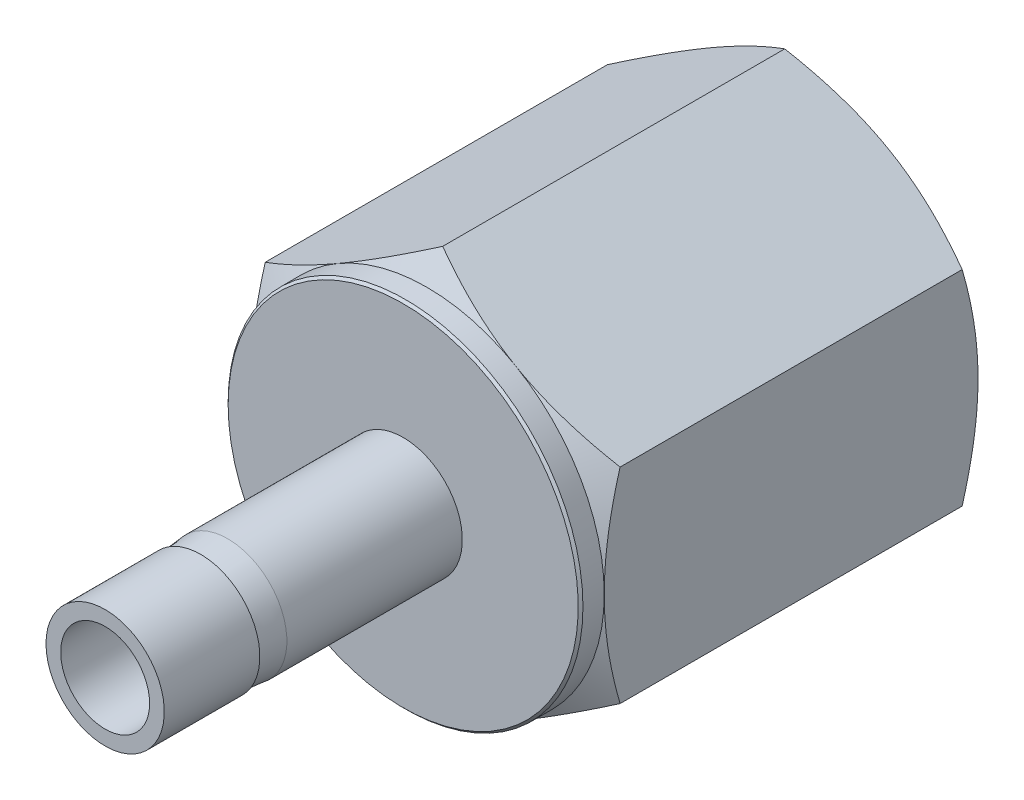
from build123d import *

# Parameters (mm, degrees)
BOSS_EXTRUDE1_DEPTH    = 21.336
SKETCH4_W              = 37.338
SKETCH4_H              = 2.3876
CHAMFER1_SIZE          = 0.127
CUT_SWEEP1_PITCH       = 1.411794907
CUT_SWEEP1_HEIGHT      = 16.513951111
CUT_SWEEP1_RADIUS      = 6.858
CUT_SWEEP1_START_ANGLE = 90


with BuildPart() as part:
    # Sketch2 → Revolve1 (revolve)
    with BuildSketch(Plane(origin=(0, 0, 0), x_dir=(0, 0, -1), z_dir=(1, 0, 0)), mode=Mode.PRIVATE) as revolve1_sk:
        Polygon((5.1308, 3.175), (5.1308, 3.048), (6.582416642, 3.175), (16.002, 3.175), (16.002, 0), (0, 0), (0, 3.175), align=None)
    revolve(revolve1_sk.sketch.rotate(Axis((0, 0, -16.002), (0, 0, 1)), 90), axis=Axis((0, 0, -16.002), (0, 0, 1)))

    # Sketch3 → Boss-Extrude1 (add)
    with BuildSketch(Plane(origin=(0, 0, -16.002), x_dir=(-1, 0, 0), z_dir=(0, 0, -1))):
        Polygon((0, 10.998522628), (-9.525, 5.499261314), (-9.525, -5.499261314), (0, -10.998522628), (9.525, -5.499261314), (9.525, 5.499261314), align=None)
    extrude(amount=BOSS_EXTRUDE1_DEPTH)

    # Sketch4 → Cut-Revolve1 (revolve, cut)
    with BuildSketch(Plane(origin=(0, 0, 0), x_dir=(0, 0, -1), z_dir=(1, 0, 0)), mode=Mode.PRIVATE) as cut_revolve1_sk:
        Polygon((16.002, 10.998522628), (16.002, 9.525), (17.272, 9.525), (18.122738686, 10.998522628), (36.487261314, 10.998522628), (37.338, 9.525), (37.338, 10.998522628), (37.338, 12.472045256), (16.002, 12.472045256), align=None)
        with Locations((18.669, 1.1938)):
            Rectangle(SKETCH4_W, SKETCH4_H)
    revolve(cut_revolve1_sk.sketch.rotate(Axis((0, 0, 0), (0, 0, -1)), 90), axis=Axis((0, 0, 0), (0, 0, -1)), mode=Mode.SUBTRACT)

    # Chamfer1
    chamfer1_edges = [part.edges().sort_by_distance(p)[0] for p in [
        (-9.525, 0, -16.002),
    ]]
    chamfer(chamfer1_edges, length=CHAMFER1_SIZE)


with BuildPart() as body_2:
    # Sketch5 → Revolve2 (revolve)
    with BuildSketch(Plane(origin=(0, 0, 0), x_dir=(0, 0, -1), z_dir=(1, 0, 0)), mode=Mode.PRIVATE) as revolve2_sk:
        Polygon((27.13228, 0), (37.338, 0), (37.338, 6.858), (27.13228, 6.540243957), align=None)
    revolve(revolve2_sk.sketch.rotate(Axis((0, 0, -27.13228), (0, 0, -1)), 270), axis=Axis((0, 0, -27.13228), (0, 0, -1)))

    # Cut-Sweep1: sweep along a helix
    with BuildLine() as cut_sweep1_path:
        # a taper helix: rise per turn along the axis 1.411111111, along the cone's slant (build123d's pitch) 1.411794907
        add(Helix(CUT_SWEEP1_PITCH, CUT_SWEEP1_HEIGHT, CUT_SWEEP1_RADIUS, center=(0, 0, -37.338), direction=(0, 0, 1), cone_angle=-1.783333333, mode=Mode.PRIVATE).rotate(Axis((0, 0, -37.338), (0, 0, 1)), CUT_SWEEP1_START_ANGLE))
    # Sketch7 → Cut-Sweep1 (sweep, cut)
    with BuildSketch(Plane(origin=(0, 0, 0), x_dir=(0, 0, -1), z_dir=(1, 0, 0))):
        Polygon((37.249805556, 7.010757259), (38.616819444, 6.934378629), (38.043555556, 5.941456448), (37.867166667, 5.941456448), align=None)
    sweep(path=cut_sweep1_path.line, is_frenet=True, mode=Mode.SUBTRACT)


with BuildPart() as part_1:
    add(part.part)

    # Combine1: cut body 2
    add(body_2.part, mode=Mode.SUBTRACT)

    # Sketch8 → Cut-Revolve2 (revolve, cut)
    with BuildSketch(Plane(origin=(0, 0, 0), x_dir=(0, 0, -1), z_dir=(1, 0, 0)), mode=Mode.PRIVATE) as cut_revolve2_sk:
        Polygon((37.338, 7.010757259), (36.11594193, 5.788699189), (37.338, 5.788699189), align=None)
        Polygon((37.338, 4.6228), (22.23516, 4.6228), (19.45750153, 0), (37.338, 0), align=None)
    revolve(cut_revolve2_sk.sketch.rotate(Axis((0, 0, 0), (0, 0, -1)), 90), axis=Axis((0, 0, 0), (0, 0, -1)), mode=Mode.SUBTRACT)


solid = part_1.part
